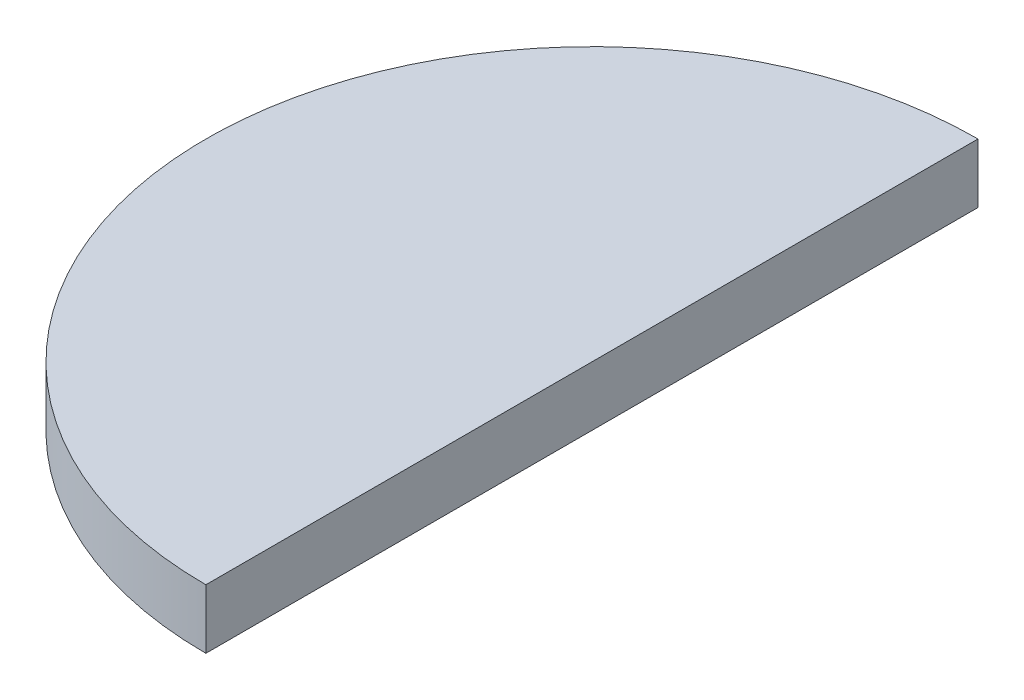
from build123d import *

# Parameters (mm, degrees)
AUFSATZ_LINEAR_AUSTRAGEN1_DEPTH = 5


with BuildPart() as part:
    # Skizze1 → Aufsatz-Linear austragen1 (new body)
    with BuildSketch(Plane(origin=(0, 0, 0), x_dir=(1, 0, 0), z_dir=(0, 1, 0))):
        with BuildLine():
            Line((0, 0), (0, -65))
            ThreePointArc((0, -65), (-32.5, -32.5), (0, 0))
        make_face()
    extrude(amount=AUFSATZ_LINEAR_AUSTRAGEN1_DEPTH)


solid = part.part
